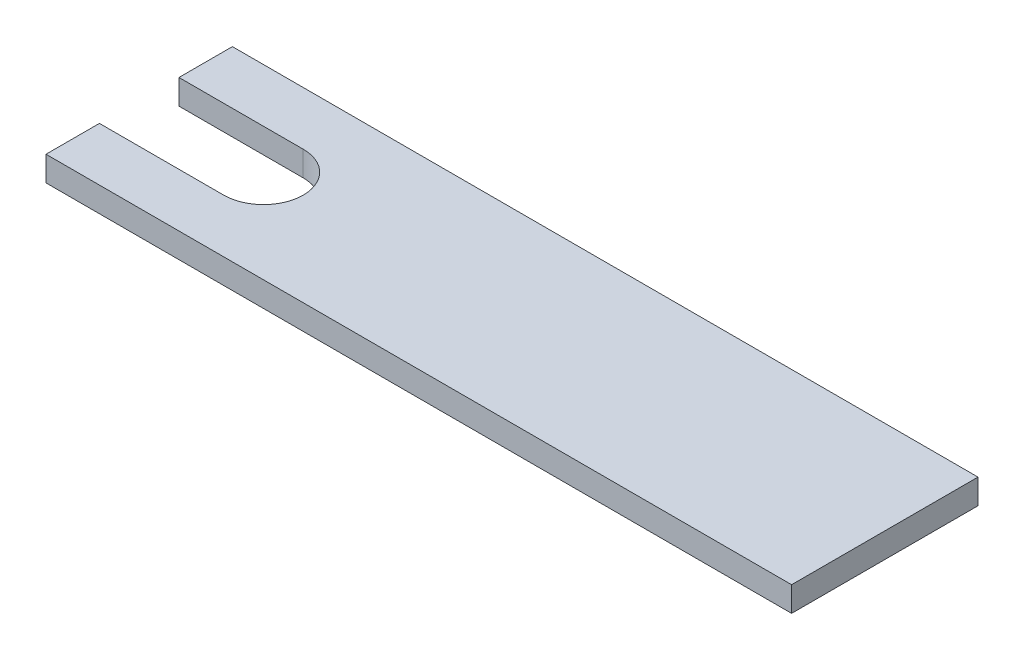
from build123d import *

# Parameters (mm, degrees)
BOSS_EXTRUDE1_DEPTH = 1


with BuildPart() as part:
    # Sketch1 → Boss-Extrude1 (new body)
    with BuildSketch(Plane(origin=(0, 0, 0), x_dir=(1, 0, 0), z_dir=(0, 1, 0))):
        with BuildLine():
            Line((0, 3.75), (0, 1.6))
            Line((0, 1.6), (5, 1.6))
            ThreePointArc((5, 1.6), (6.6, 0), (5, -1.6))
            Line((5, -1.6), (0, -1.6))
            Line((0, -1.6), (0, -3.75))
            Line((0, -3.75), (30, -3.75))
            Line((30, -3.75), (30, 3.75))
            Line((30, 3.75), (0, 3.75))
        make_face()
    extrude(amount=BOSS_EXTRUDE1_DEPTH)


solid = part.part
